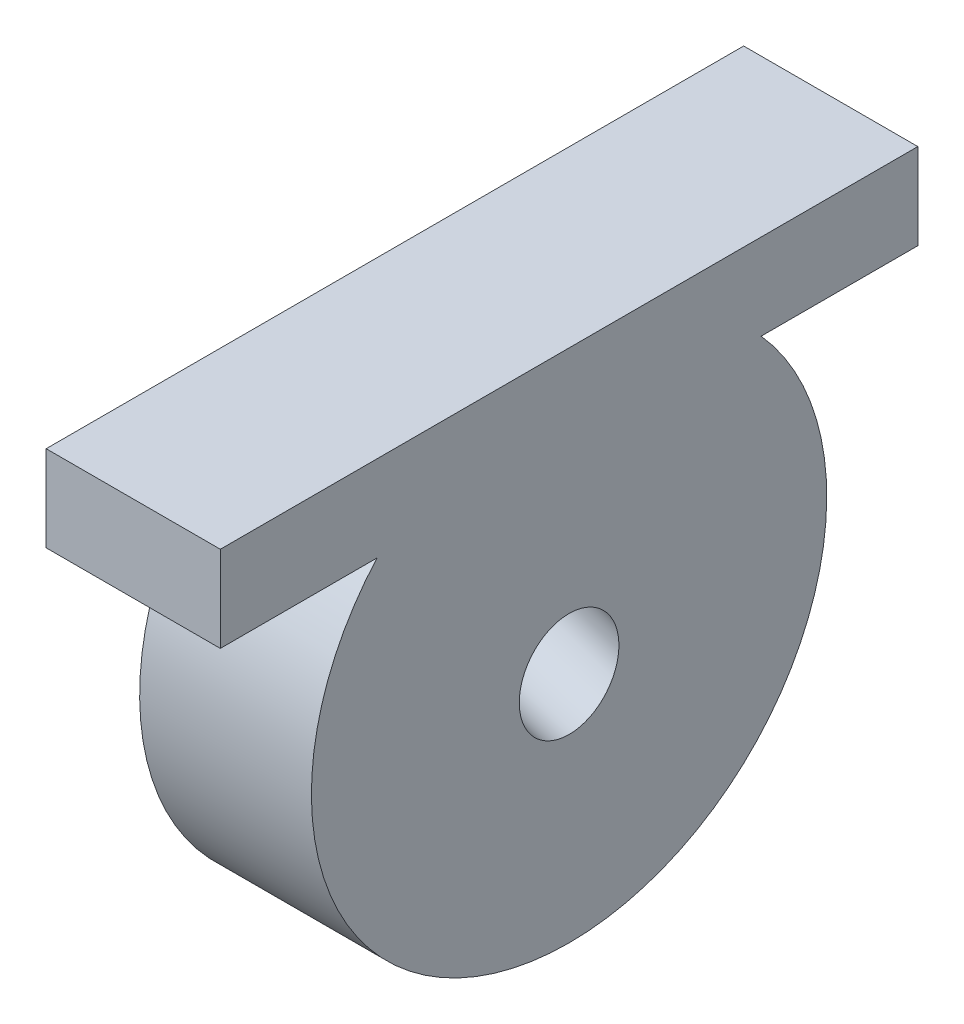
from build123d import *

# Parameters (mm, degrees)
SKETCH3_W            = 25.753050404
SKETCH3_H            = 103.137359271
BOSS_EXTRUDE1_DEPTH  = 12.7
SKETCH4_R            = 38.1
BOSS_EXTRUDE2_DEPTH  = 25.4
CUT_SWEEP1_PROFILE_R = 7.366


with BuildPart() as part:
    # Sketch3 → Boss-Extrude1 (new body)
    with BuildSketch(Plane(origin=(0, 717.636591226, 0), x_dir=(-1, 0, 0), z_dir=(0, -1, 0))):
        with Locations((-511.2749233, -660.547915429)):
            Rectangle(SKETCH3_W, SKETCH3_H)
    extrude(amount=BOSS_EXTRUDE1_DEPTH)

    # Sketch4 → Boss-Extrude2 (add)
    with BuildSketch(Plane(origin=(524.151448502, 0, 0), x_dir=(0, 0, -1), z_dir=(1, 0, 0))):
        with Locations((-660.547915428, 679.536591226)):
            Circle(SKETCH4_R)
    extrude(amount=-BOSS_EXTRUDE2_DEPTH)

    # Cut-Sweep1: sweep along a path in Sketch5
    with BuildLine(Plane.XY.offset(660.547915428)) as cut_sweep1_path:
        Line((472.45049051, 692.709335123), (547.766548789, 668.191368615))
    # Cut-Sweep1 profile (on start of the path) → Cut-Sweep1 (sweep, cut)
    with BuildSketch(Plane(origin=(472.45049051, 692.709335123, 660.547915428), x_dir=(0.309545628, 0.95088459, 0), z_dir=(0.95088459, -0.309545628, 0))):
        Circle(CUT_SWEEP1_PROFILE_R)
    sweep(path=cut_sweep1_path.line, mode=Mode.SUBTRACT)


solid = part.part
